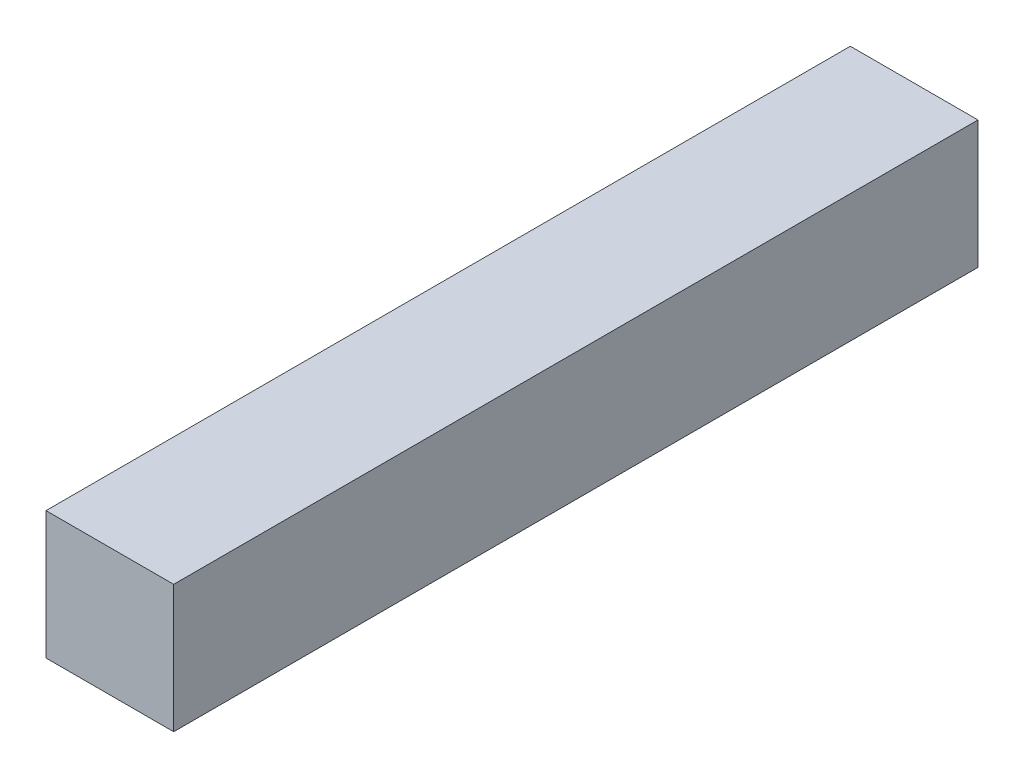
from build123d import *

# Parameters (mm, degrees)
SKETCH1_W           = 3.175
SKETCH1_H           = 3.175
BOSS_EXTRUDE1_DEPTH = 20


with BuildPart() as part:
    # Sketch1 → Boss-Extrude1 (new body)
    with BuildSketch(Plane.XY):
        Rectangle(SKETCH1_W, SKETCH1_H)
    extrude(amount=BOSS_EXTRUDE1_DEPTH)


solid = part.part
